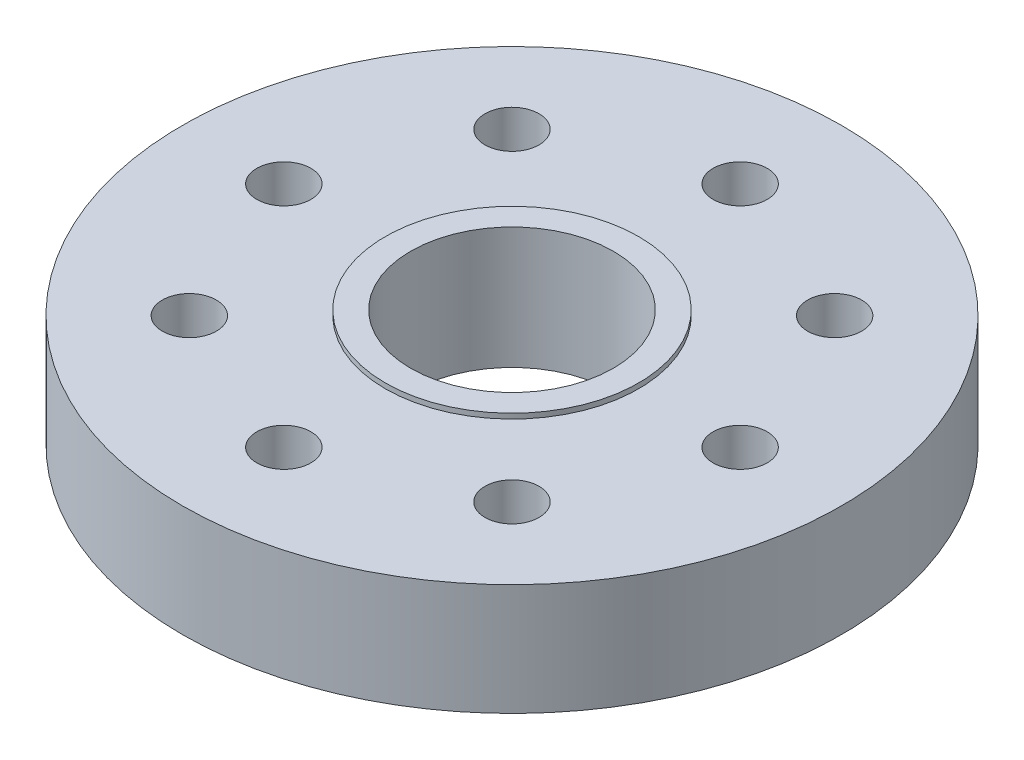
from build123d import *
from build123d.topology import SkipClean

# Parameters (mm, degrees)
CROQUIS1_R              = 9.75
CROQUIS1_R_2            = 0.8
CROQUIS1_R_3            = 3
SALIENTE_EXTRUIR1_DEPTH = 1.65
CROQUIS1_3_R            = 3.75
CROQUIS1_3_R_2          = 3
SALIENTE_EXTRUIR2_DEPTH = 1.8
CROQUIS2_R              = 2
CORTAR_EXTRUIR3_DEPTH   = 1.8
SALIENTE_EXTRUIR3_START = 0.15
CROQUIS3_R              = 4.4
CROQUIS3_R_2            = 3
SALIENTE_EXTRUIR3_DEPTH = 0.15


with BuildPart() as part:
    # Croquis1 → Saliente-Extruir1 (new, symmetric)
    with BuildSketch(Plane(origin=(0, 0, 0), x_dir=(1, 0, 0), z_dir=(0, 1, 0))):
        Circle(CROQUIS1_R)
        with Locations((-4.772970773, -4.772970773)):
            Circle(CROQUIS1_R_2, mode=Mode.SUBTRACT)
        with Locations((0, -6.75)):
            Circle(CROQUIS1_R_2, mode=Mode.SUBTRACT)
        with Locations((4.772970773, -4.772970773)):
            Circle(CROQUIS1_R_2, mode=Mode.SUBTRACT)
        with Locations((-6.75, 0)):
            Circle(CROQUIS1_R_2, mode=Mode.SUBTRACT)
        with Locations((-4.772970773, 4.772970773)):
            Circle(CROQUIS1_R_2, mode=Mode.SUBTRACT)
        with Locations((4.772970773, 4.772970773)):
            Circle(CROQUIS1_R_2, mode=Mode.SUBTRACT)
        with Locations((6.75, 0)):
            Circle(CROQUIS1_R_2, mode=Mode.SUBTRACT)
        with Locations((0, 6.75)):
            Circle(CROQUIS1_R_2, mode=Mode.SUBTRACT)
        Circle(CROQUIS1_R_3, mode=Mode.SUBTRACT)
    extrude(amount=SALIENTE_EXTRUIR1_DEPTH, both=True)

    # Croquis1_3 → Saliente-Extruir2 (add, symmetric)
    with BuildSketch(Plane(origin=(0, 0, 0), x_dir=(1, 0, 0), z_dir=(0, 1, 0))):
        Circle(CROQUIS1_3_R)
        Circle(CROQUIS1_3_R_2, mode=Mode.SUBTRACT)
    extrude(amount=SALIENTE_EXTRUIR2_DEPTH, both=True)

    # Croquis2 → Cortar-Extruir3 (cut)
    with BuildSketch(Plane.XZ.offset(1.65)):
        with BuildLine():
            ThreePointArc((8.493703704, -0.979539378), (4.75, 0), (8.493703704, 0.979539378))
            ThreePointArc((8.493703704, 0.979539378), (7.998376267, 3.021336972), (7.02006773, 4.880691454))
            ThreePointArc((7.02006773, 4.880691454), (7.02224488, 4.826850669), (7.022970773, 4.772970773))
            ThreePointArc((7.022970773, 4.772970773), (3.536549224, 3.434856062), (5.232419794, 6.761973314))
            ThreePointArc((5.232419794, 6.761973314), (3.619603246, 7.746029457), (1.830044014, 8.351852424))
            ThreePointArc((1.830044014, 8.351852424), (2.27157135, 7.69926144), (2.426776695, 6.926776695))
            ThreePointArc((2.426776695, 6.926776695), (-0.457693454, 5.132978336), (-0.79093586, 8.513337798))
            ThreePointArc((-0.79093586, 8.513337798), (-2.79976514, 8.078602303), (-4.646803784, 7.177026863))
            ThreePointArc((-4.646803784, 7.177026863), (-3.042587429, 6.716523558), (-2.346194078, 5.199747468))
            ThreePointArc((-2.346194078, 5.199747468), (-4.673942073, 3.226784911), (-6.238775329, 5.846381992))
            ThreePointArc((-6.238775329, 5.846381992), (-3.594367278, -7.757771837), (8.493703704, -0.979539378))
        make_face()
        with BuildLine():
            ThreePointArc((0.327362602, -4.387805115), (1.405670554, -5.100169462), (1.823223305, -6.323223305))
            ThreePointArc((1.823223305, -6.323223305), (-1.443575646, -7.870873271), (-0.571997114, -4.362661951))
            ThreePointArc((-0.571997114, -4.362661951), (-1.892548808, -3.972185671), (-3.027723734, -3.192630419))
            ThreePointArc((-3.027723734, -3.192630419), (-2.837706698, -3.6646868), (-2.772970773, -4.169417382))
            ThreePointArc((-2.772970773, -4.169417382), (-6.562508569, -5.062476438), (-3.57052525, -2.571254448))
            ThreePointArc((-3.57052525, -2.571254448), (-1.350868035, 4.187499917), (4.4, 0))
            ThreePointArc((4.4, 0), (3.224933755, -2.993292882), (0.327362602, -4.387805115))
        make_face(mode=Mode.SUBTRACT)
        with Locations((4.596194078, -4.596194078)):
            Circle(CROQUIS2_R, mode=Mode.SUBTRACT)
        with Locations((-6.5, 0.603553391)):
            Circle(CROQUIS2_R, mode=Mode.SUBTRACT)
    extrude(amount=-CORTAR_EXTRUIR3_DEPTH, mode=Mode.SUBTRACT)

    # Croquis3 → Saliente-Extruir3 (add)
    with SkipClean():  # the faces are left unmerged after this step: merging them gives an invalid solid
        with BuildSketch(Plane.XZ.offset(1.65).offset(SALIENTE_EXTRUIR3_START)):
            Circle(CROQUIS3_R)
            Circle(CROQUIS3_R_2, mode=Mode.SUBTRACT)
        extrude(amount=-SALIENTE_EXTRUIR3_DEPTH)


solid = part.part
